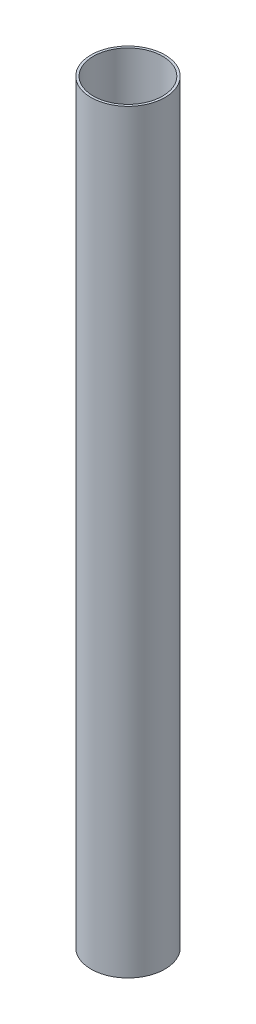
from build123d import *

# Parameters (mm, degrees)
SKETCH1_R      = 45.847
SKETCH1_R_2    = 42.926
EXTRUDE1_DEPTH = 936.625


with BuildPart() as part:
    # Sketch1 → Extrude1 (new body)
    with BuildSketch(Plane(origin=(0, 0, 0), x_dir=(1, 0, 0), z_dir=(0, 1, 0))):
        Circle(SKETCH1_R)
        Circle(SKETCH1_R_2, mode=Mode.SUBTRACT)
    extrude(amount=EXTRUDE1_DEPTH)


solid = part.part
